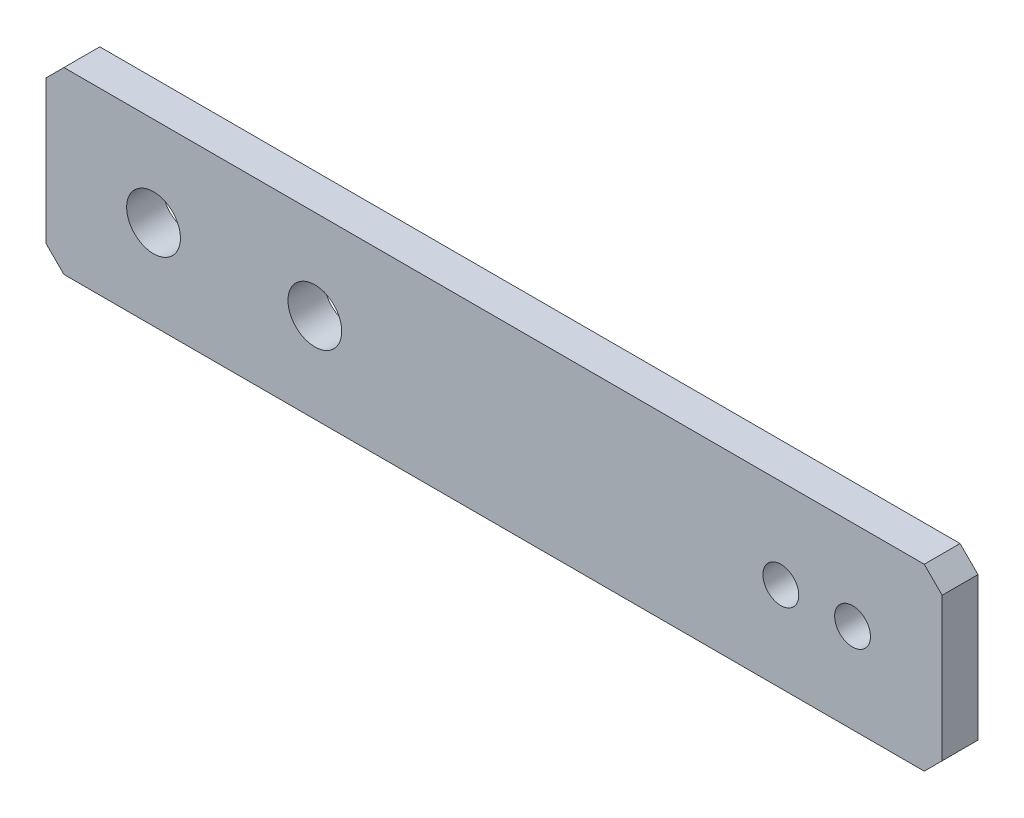
from build123d import *

# Parameters (mm, degrees)
SKETCH1_W           = 50
SKETCH1_H           = 10
SKETCH1_R           = 1.5
SKETCH1_R_2         = 1
BOSS_EXTRUDE1_DEPTH = 2
CHAMFER1_SIZE       = 1


with BuildPart() as part:
    # Sketch1 → Boss-Extrude1 (new body)
    with BuildSketch(Plane.XY):
        with Locations((10.829307568, 4.380032206)):
            Rectangle(SKETCH1_W, SKETCH1_H)
        with Locations((-8.170692432, 4.380032206)):
            Circle(SKETCH1_R, mode=Mode.SUBTRACT)
        with Locations((0.829307568, 4.380032206)):
            Circle(SKETCH1_R, mode=Mode.SUBTRACT)
        with Locations((26.829307568, 4.380032206)):
            Circle(SKETCH1_R_2, mode=Mode.SUBTRACT)
        with Locations((30.829307568, 4.380032206)):
            Circle(SKETCH1_R_2, mode=Mode.SUBTRACT)
    extrude(amount=BOSS_EXTRUDE1_DEPTH)

    # Chamfer1
    chamfer1_edges = [part.edges().sort_by_distance(p)[0] for p in [
        (-14.170692432, 9.380032206, 1),
        (35.829307568, 9.380032206, 1),
        (35.829307568, -0.619967794, 1),
        (-14.170692432, -0.619967794, 1),
    ]]
    chamfer(chamfer1_edges, length=CHAMFER1_SIZE)


solid = part.part
